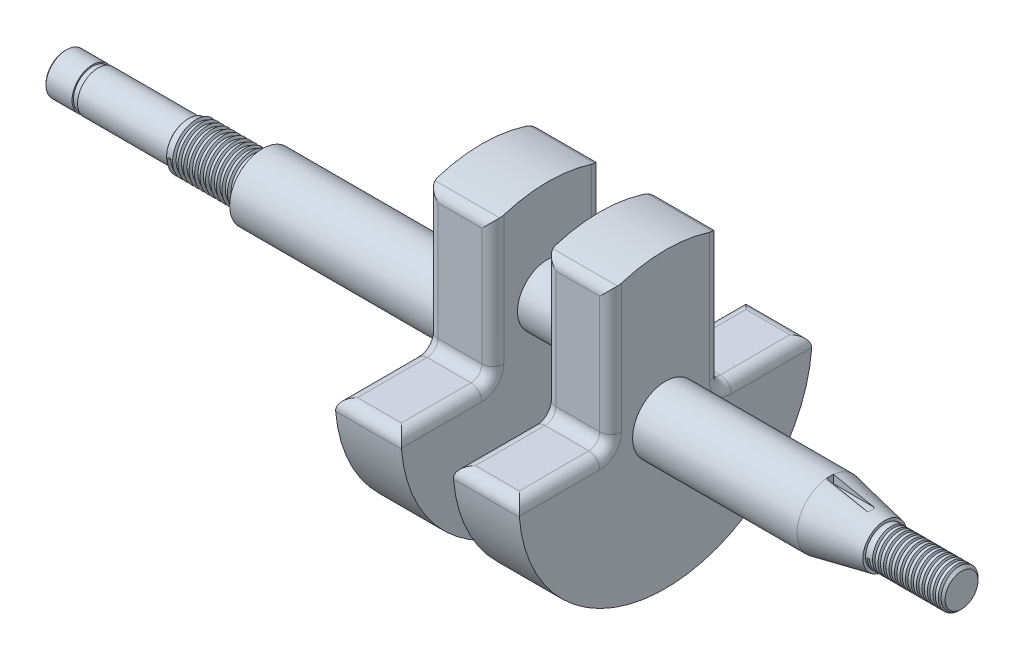
from build123d import *

# Parameters (mm, degrees)
SKETCH1_R                = 6
BOSS_EXTRUDE1_DEPTH      = 30
SKETCH3_R                = 6
SKETCH2_R                = 4
BOSS_EXTRUDE2_DEPTH      = 12
SKETCH5_R                = 5.5
BOSS_EXTRUDE3_DEPTH      = 4.75
BOSS_EXTRUDE3_DEPTH_BACK = 4.75
FILLET2_R                = 2
SKETCH7_R                = 6
BOSS_EXTRUDE5_DEPTH      = 40
SKETCH8_R                = 4
BOSS_EXTRUDE6_DEPTH      = 36
CHAMFER1_SIZE            = 0.5
SKETCH9_R                = 4
SKETCH9_R_2              = 3.5
CUT_EXTRUDE1_DEPTH       = 1
SKETCH10_R               = 3.5
BOSS_EXTRUDE7_DEPTH      = 14
CHAMFER2_SIZE            = 0.5
CUT_SWEEP1_PITCH         = 1
CUT_SWEEP1_HEIGHT        = 13.5
CUT_SWEEP1_RADIUS        = 3.5
CUT_EXTRUDE3_DEPTH       = 19
SWEEP1_PITCH             = 1
SWEEP1_HEIGHT            = 12.75
SWEEP1_RADIUS            = 4
SKETCH26_R               = 4
SKETCH26_R_2             = 3.7
CUT_EXTRUDE5_DEPTH       = 0.2
SKETCH27_R               = 4
SKETCH27_R_2             = 3.75
CUT_EXTRUDE6_DEPTH       = 22.3


with BuildPart() as part:
    # Sketch1 → Boss-Extrude1 (new body)
    with BuildSketch(Plane(origin=(0, 0, 0), x_dir=(0, 0, -1), z_dir=(1, 0, 0))):
        Circle(SKETCH1_R)
    extrude(amount=BOSS_EXTRUDE1_DEPTH)

    # Sketch3 → Loft1 section 0
    with BuildSketch(Plane(origin=(30, 0, 0), x_dir=(0, 0, -1), z_dir=(1, 0, 0))):
        Circle(SKETCH3_R)
    # Sketch2 → Loft1 section 1
    with BuildSketch(Plane(origin=(40, 0, 0), x_dir=(0, 0, -1), z_dir=(1, 0, 0))):
        Circle(SKETCH2_R)
    loft()

    # Sketch4 → Boss-Extrude2 (add)
    with BuildSketch(Plane.ZY):
        with BuildLine():
            Line((10, 0), (10, 24.810532038))
            ThreePointArc((10, 24.810532038), (0, 26.75), (-10, 24.810532038))
            Line((-10, 24.810532038), (-10, 0))
            Line((-10, 0), (-26.75, 0))
            ThreePointArc((-26.75, 0), (0, -26.75), (26.75, 0))
            Line((26.75, 0), (10, 0))
        make_face()
    boss_extrude2 = extrude(amount=BOSS_EXTRUDE2_DEPTH)

    # Sketch5 → Boss-Extrude3 (add, two sides)
    with BuildSketch(Plane.ZY.offset(16.75)) as boss_extrude3_sk:
        with Locations((0, 9)):
            Circle(SKETCH5_R)
    extrude(amount=BOSS_EXTRUDE3_DEPTH)
    extrude(boss_extrude3_sk.sketch, amount=-BOSS_EXTRUDE3_DEPTH_BACK)

    # Mirror7: Boss-Extrude2 across plane
    add(boss_extrude2.mirror(Plane.ZY.offset(16.75)))

    # Fillet2
    fillet2_edges = [part.edges().sort_by_distance(p)[0] for p in [
        (0, 0, 18.375),
        (-6, 0, 26.75),
        (0, 12.405266019, 10),
        (-6, 0, 10),
        (-6, 24.810532038, 10),
        (0, 12.405266019, -10),
        (-6, 24.810532038, -10),
        (0, 0, -18.375),
        (-6, 0, -10),
        (-6, 0, -26.75),
        (-12, 0, 18.375),
        (-12, 12.405266019, 10),
        (-12, 12.405266019, -10),
        (-12, 0, -18.375),
        (-21.5, 0, 18.375),
        (-27.5, 0, 10),
        (-27.5, 0, 26.75),
        (-21.5, 0, -18.375),
        (-27.5, 0, -26.75),
        (-21.5, 12.405266019, -10),
        (-27.5, 0, -10),
        (-27.5, 24.810532038, -10),
        (-21.5, 12.405266019, 10),
        (-27.5, 24.810532038, 10),
        (-33.5, 0, 18.375),
        (-33.5, 12.405266019, 10),
        (-33.5, 12.405266019, -10),
        (-33.5, 0, -18.375),
    ]]
    fillet(fillet2_edges, radius=FILLET2_R)

    # Sketch7 → Boss-Extrude5 (add)
    with BuildSketch(Plane.ZY.offset(33.5)):
        Circle(SKETCH7_R)
    extrude(amount=BOSS_EXTRUDE5_DEPTH)

    # Sketch8 → Boss-Extrude6 (add)
    with BuildSketch(Plane.ZY.offset(73.5)):
        Circle(SKETCH8_R)
    extrude(amount=BOSS_EXTRUDE6_DEPTH)

    # Chamfer1
    chamfer1_edges = [part.edges().sort_by_distance(p)[0] for p in [
        (-109.5, 0, -4),
    ]]
    chamfer(chamfer1_edges, length=CHAMFER1_SIZE)

    # Sketch9 → Cut-Extrude1 (cut)
    with BuildSketch(Plane.ZY.offset(104.5)):
        Circle(SKETCH9_R)
        Circle(SKETCH9_R_2, mode=Mode.SUBTRACT)
    extrude(amount=-CUT_EXTRUDE1_DEPTH, mode=Mode.SUBTRACT)

    # Sketch10 → Boss-Extrude7 (add)
    with BuildSketch(Plane(origin=(40, 0, 0), x_dir=(0, 0, -1), z_dir=(1, 0, 0))):
        Circle(SKETCH10_R)
    extrude(amount=BOSS_EXTRUDE7_DEPTH)

    # Chamfer2
    chamfer2_edges = [part.edges().sort_by_distance(p)[0] for p in [
        (54, 0, 3.5),
    ]]
    chamfer(chamfer2_edges, length=CHAMFER2_SIZE)

    # Cut-Sweep1: sweep along a helix
    with BuildLine() as cut_sweep1_path:
        Helix(CUT_SWEEP1_PITCH, CUT_SWEEP1_HEIGHT, CUT_SWEEP1_RADIUS, center=(54, 0, 0), direction=(-1, 0, 0))
    # Sketch17 → Cut-Sweep1 (sweep, cut)
    with BuildSketch(Plane(origin=(54, 0, -3.5), x_dir=(-0.998967711, 0.0454259, 0), z_dir=(-0.0454259, -0.998967711, 0))):
        Polygon((0.007737828, -0.399970273), (0.35414799, 0.200029727), (-0.338672333, 0.200029727), align=None)
    sweep(path=cut_sweep1_path.line, is_frenet=True, mode=Mode.SUBTRACT)

    # Sketch24 → Cut-Extrude3 (cut)
    with BuildSketch(Plane(origin=(30, 0, 0), x_dir=(0, 0, -1), z_dir=(1, 0, 0))):
        with BuildLine():
            Line((-0.65, 5.964687754), (-0.65, 4.464687754))
            Line((-0.65, 4.464687754), (0.65, 4.464687754))
            Line((0.65, 4.464687754), (0.65, 5.964687754))
            ThreePointArc((0.65, 5.964687754), (0, 6), (-0.65, 5.964687754))
        make_face()
    extrude(amount=CUT_EXTRUDE3_DEPTH, mode=Mode.SUBTRACT)

    # Sweep1: sweep along a helix
    with BuildLine() as sweep1_path:
        Helix(SWEEP1_PITCH, SWEEP1_HEIGHT, SWEEP1_RADIUS, center=(-86.5, 0, 0), direction=(1, 0, 0))
    # Sketch21 → Sweep1 (sweep)
    with BuildSketch(Plane(origin=(-86.5, 0, 4), x_dir=(-0.999209367, -0.039757277, 0), z_dir=(0.039757277, -0.999209367, 0))):
        Polygon((0, -0.4), (0.346410162, 0.2), (-0.346410162, 0.2), align=None)
    sweep(path=sweep1_path.line, is_frenet=True)

    # Sketch26 → Cut-Extrude5 (cut)
    with BuildSketch(Plane.ZY.offset(87)):
        Circle(SKETCH26_R)
        Circle(SKETCH26_R_2, mode=Mode.SUBTRACT)
    extrude(amount=CUT_EXTRUDE5_DEPTH, mode=Mode.SUBTRACT)

    # Sketch27 → Cut-Extrude6 (cut)
    with BuildSketch(Plane(origin=(-87.2, 0, 0), x_dir=(0, 0, -1), z_dir=(1, 0, 0))):
        Circle(SKETCH27_R)
        Circle(SKETCH27_R_2, mode=Mode.SUBTRACT)
    extrude(amount=-CUT_EXTRUDE6_DEPTH, mode=Mode.SUBTRACT)


solid = part.part
